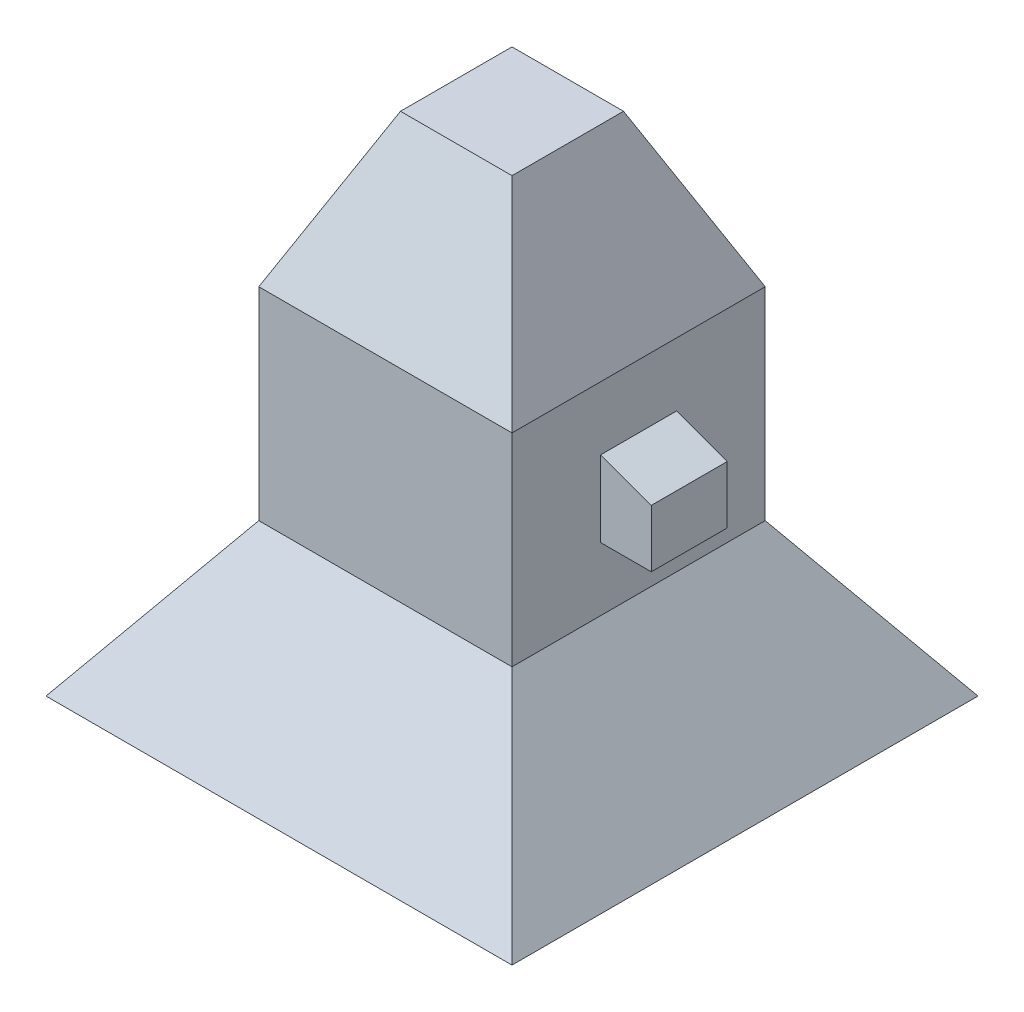
from build123d import *

# Parameters (mm, degrees)
SKETCH1_W           = 2540
SKETCH1_H           = 2540
BOSS_EXTRUDE1_DEPTH = 2032
SKETCH3_W           = 2540
SKETCH3_H           = 2540
BOSS_EXTRUDE2_DEPTH = 1524
BOSS_EXTRUDE2_TAPER = 25
SKETCH6_W           = 2540
SKETCH6_H           = 2540
BOSS_EXTRUDE3_DEPTH = 1524
BOSS_EXTRUDE3_TAPER = -35
SKETCH7_W           = 3658.232576464
SKETCH7_H           = 3658.232576464
CUT_EXTRUDE1_DEPTH  = 508
CUT_EXTRUDE1_TAPER  = 35
SKETCH8_W           = 762
SKETCH8_H           = 762
BOSS_EXTRUDE4_DEPTH = 508
DRAFT1_ANGLE        = 20


with BuildPart() as part:
    # Sketch1 → Boss-Extrude1 (new body)
    with BuildSketch(Plane(origin=(0, 0, 0), x_dir=(1, 0, 0), z_dir=(0, 1, 0))):
        with Locations((1270, 1270)):
            Rectangle(SKETCH1_W, SKETCH1_H)
    extrude(amount=BOSS_EXTRUDE1_DEPTH)

    # Sketch3 → Boss-Extrude2 (add)
    with BuildSketch(Plane(origin=(0, 2032, 0), x_dir=(1, 0, 0), z_dir=(0, 1, 0))):
        with Locations((1270, 1270)):
            Rectangle(SKETCH3_W, SKETCH3_H)
    extrude(amount=BOSS_EXTRUDE2_DEPTH, taper=BOSS_EXTRUDE2_TAPER)

    # Sketch6 → Boss-Extrude3 (add)
    with BuildSketch(Plane.XZ):
        with Locations((1270, -1270)):
            Rectangle(SKETCH6_W, SKETCH6_H)
    extrude(amount=BOSS_EXTRUDE3_DEPTH, taper=BOSS_EXTRUDE3_TAPER)

    # Sketch7 → Cut-Extrude1 (cut)
    with BuildSketch(Plane.XZ.offset(1524)):
        with Locations((1270, -1270)):
            Rectangle(SKETCH7_W, SKETCH7_H)
    extrude(amount=-CUT_EXTRUDE1_DEPTH, taper=CUT_EXTRUDE1_TAPER, mode=Mode.SUBTRACT)

    # Sketch8 → Boss-Extrude4 (add)
    with BuildSketch(Plane(origin=(2540, 0, 0), x_dir=(0, 0, -1), z_dir=(1, 0, 0))):
        with Locations((1270, 1016)):
            Rectangle(SKETCH8_W, SKETCH8_H)
    extrude(amount=BOSS_EXTRUDE4_DEPTH)

    # Draft1
    draft1_faces = [part.faces().sort_by_distance(p)[0] for p in [
        (2794, 1397, -1270),
    ]]
    draft(draft1_faces, Plane(origin=(2540, 2032, 0), x_dir=(0, 0, 1), z_dir=(1, 0, 0)), DRAFT1_ANGLE)


solid = part.part
